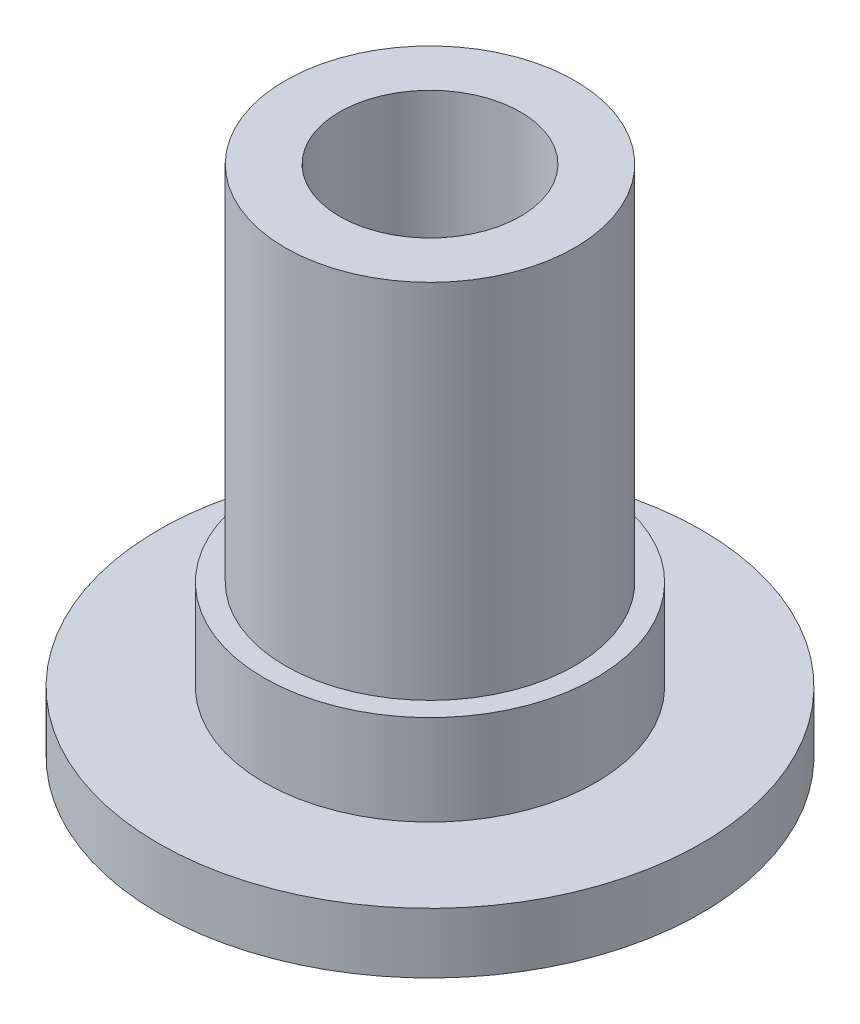
from build123d import *

# Parameters (mm, degrees)
SKETCH_1_R          = 9
EXTRUDE_1_DEPTH     = 2
SKETCH_2_R          = 5.5
EXTRUDE_2_DEPTH     = 3
SKETCH_5_R          = 4.8
EXTRUDE_4_DEPTH     = 12
SKETCH_6_R          = 3
CUT_EXTRUDE_2_DEPTH = 18


with BuildPart() as part:
    # Эскиз1 → Бобышка-Вытянуть1 (new body)
    with BuildSketch(Plane(origin=(0, 0, 0), x_dir=(1, 0, 0), z_dir=(0, 1, 0))):
        Circle(SKETCH_1_R)
    extrude(amount=EXTRUDE_1_DEPTH)

    # Эскиз2 → Бобышка-Вытянуть2 (add)
    with BuildSketch(Plane(origin=(0, 2, 0), x_dir=(1, 0, 0), z_dir=(0, 1, 0))):
        Circle(SKETCH_2_R)
    extrude(amount=EXTRUDE_2_DEPTH)

    # Эскиз5 → Бобышка-Вытянуть4 (add)
    with BuildSketch(Plane(origin=(0, 5, 0), x_dir=(1, 0, 0), z_dir=(0, 1, 0))):
        Circle(SKETCH_5_R)
    extrude(amount=EXTRUDE_4_DEPTH)

    # Эскиз6 → Вырез-Вытянуть2 (cut, through all)
    with BuildSketch(Plane(origin=(0, 17, 0), x_dir=(1, 0, 0), z_dir=(0, 1, 0))):
        Circle(SKETCH_6_R)
    extrude(amount=-CUT_EXTRUDE_2_DEPTH, mode=Mode.SUBTRACT)


solid = part.part
